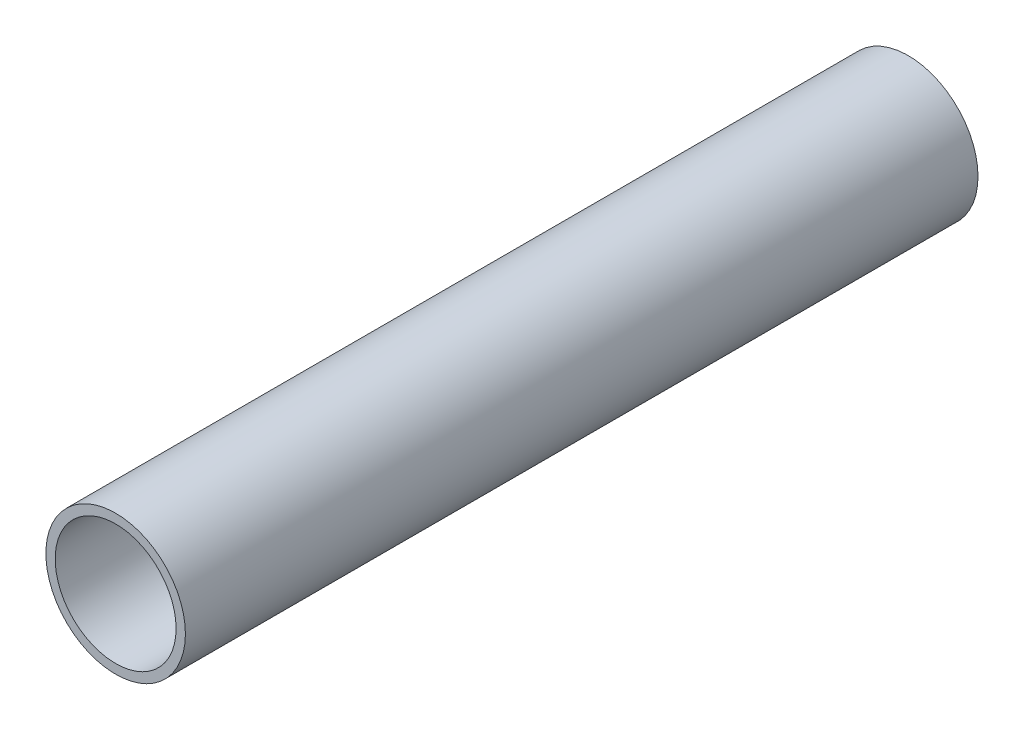
from build123d import *

# Parameters (mm, degrees)
SKETCH1_R           = 9.525
SKETCH1_R_2         = 8.255
BOSS_EXTRUDE1_DEPTH = 108.204


with BuildPart() as part:
    # Sketch1 → Boss-Extrude1 (new body)
    with BuildSketch(Plane.XY):
        Circle(SKETCH1_R)
        Circle(SKETCH1_R_2, mode=Mode.SUBTRACT)
    extrude(amount=BOSS_EXTRUDE1_DEPTH)


solid = part.part
